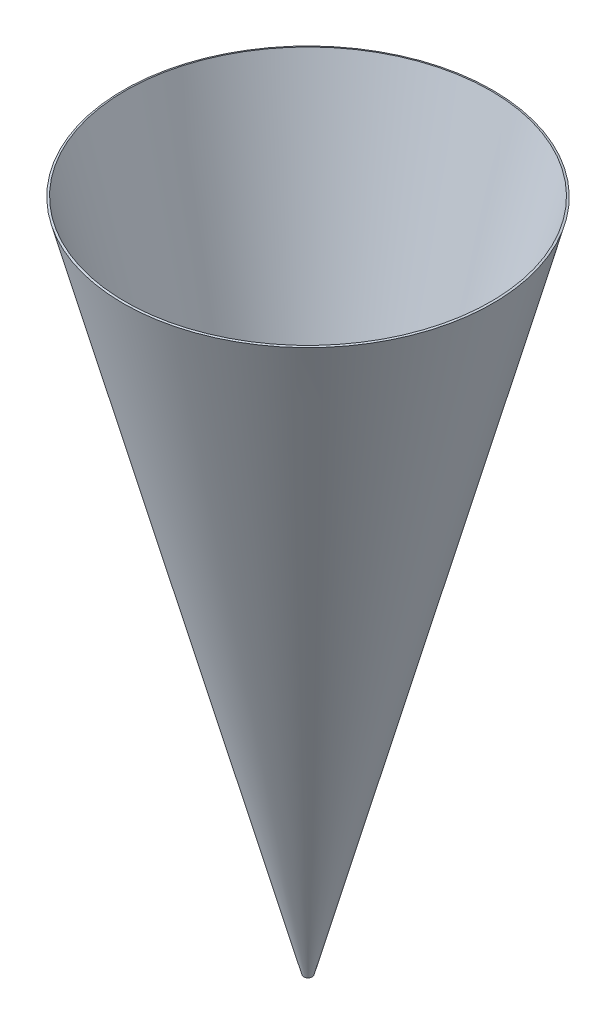
from build123d import *


with BuildPart() as part:
    # Sketch1 → Revolve-Thin1 (revolve)
    with BuildSketch(Plane.XY):
        Polygon((0.0635, 0), (2.742991924, 10), (2.71401415, 10.007764571), (0.034522225, 0.007764571), align=None)
    revolve(axis=Axis((0, 0, 0), (0, 1, 0)))


solid = part.part
